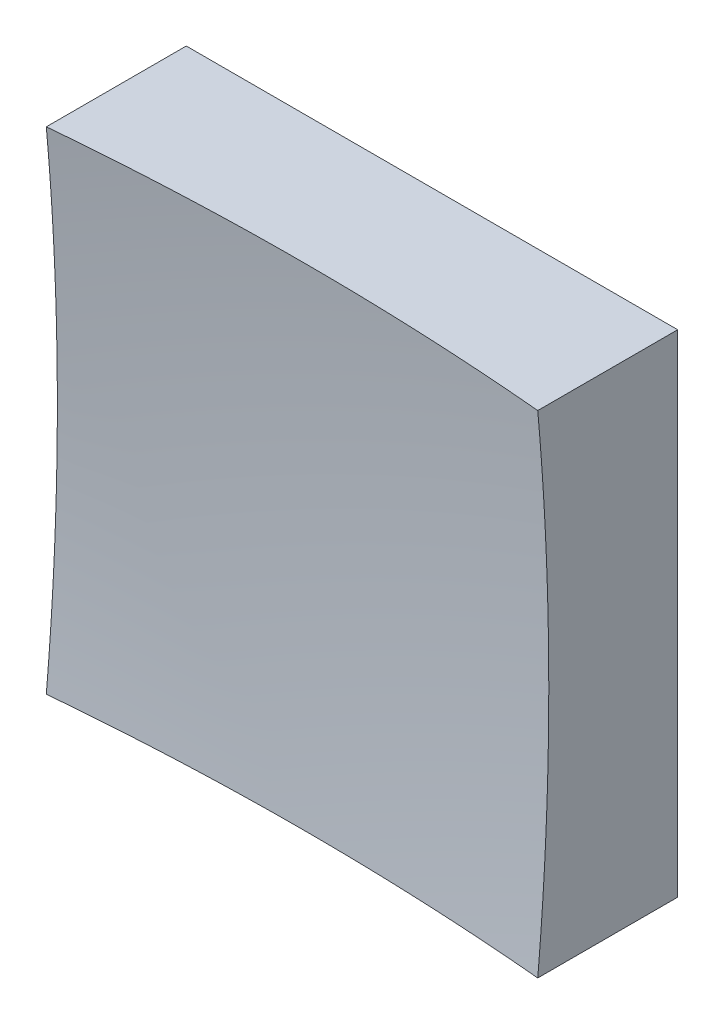
from build123d import *

# Parameters (mm, degrees)
SKETCH_1_W      = 12.5
SKETCH_1_H      = 12.5
EXTRUDE_1_DEPTH = 10


with BuildPart() as part:
    # 草图1 → 凸台-拉伸1 (new body)
    with BuildSketch(Plane.XY):
        Rectangle(SKETCH_1_W, SKETCH_1_H)
    extrude(amount=EXTRUDE_1_DEPTH)

    # 草图2 → 切除-旋转2 (revolve, cut)
    with BuildSketch(Plane(origin=(0, 0, 0), x_dir=(1, 0, 0), z_dir=(0, 1, 0))):
        with BuildLine():
            Line((68.239182327, -57.398269476), (0, -57.398269476))
            Line((0, -57.398269476), (0, -3))
            ThreePointArc((0, -3), (43.634154417, -18.263717989), (68.239182327, -57.398269476))
        make_face()
    revolve(axis=Axis((0, 0, 57.398269476), (0, 0, -1)), mode=Mode.SUBTRACT)


solid = part.part
